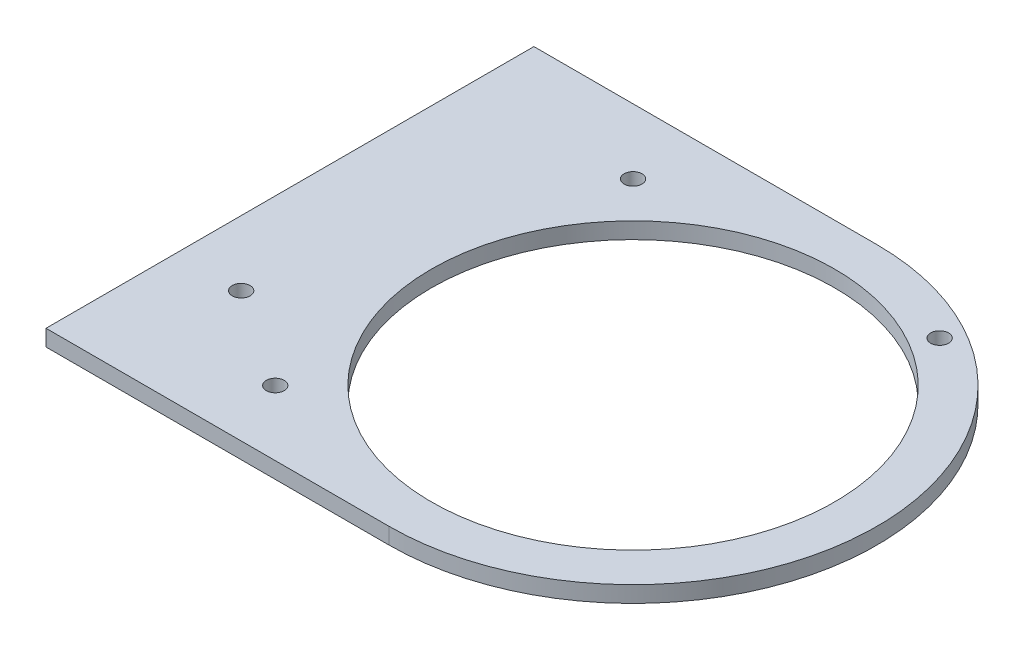
from build123d import *

# Parameters (mm, degrees)
SKETCH2_W           = 120.952956328
SKETCH2_H           = 3.175
BOSS_EXTRUDE1_DEPTH = 95.25
SKETCH3_R           = 39.37
CUT_EXTRUDE2_DEPTH  = 4.175
CUT_EXTRUDE3_DEPTH  = 4.175
SKETCH8_R           = 1.75
CUT_EXTRUDE7_DEPTH  = 4.175
SKETCH10_R          = 1.75
CUT_EXTRUDE9_DEPTH  = 4.175
SKETCH11_W          = 6.35
SKETCH11_H          = 95.25
CUT_EXTRUDE10_DEPTH = 4.175
SKETCH12_R          = 1.75
CUT_EXTRUDE11_DEPTH = 4.175


with BuildPart() as part:
    # Sketch2 → Boss-Extrude1 (new body)
    with BuildSketch(Plane.XY):
        with Locations((98.782063621, 1.5875)):
            Rectangle(SKETCH2_W, SKETCH2_H)
    extrude(amount=BOSS_EXTRUDE1_DEPTH)

    # Sketch3 → Cut-Extrude2 (cut, through all)
    with BuildSketch(Plane(origin=(0, 3.175, 0), x_dir=(1, 0, 0), z_dir=(0, 1, 0))):
        with Locations((111.633541785, -47.625)):
            Circle(SKETCH3_R)
    extrude(amount=-CUT_EXTRUDE2_DEPTH, mode=Mode.SUBTRACT)

    # Sketch4 → Cut-Extrude3 (cut, through all)
    with BuildSketch(Plane(origin=(0, 3.175, 0), x_dir=(1, 0, 0), z_dir=(0, 1, 0))):
        with BuildLine():
            Line((111.633541785, -95.25), (179.051442703, -95.25))
            Line((179.051442703, -95.25), (179.051442703, 0))
            Line((179.051442703, 0), (111.633541785, 0))
            ThreePointArc((111.633541785, 0), (159.258541785, -47.625), (111.633541785, -95.25))
        make_face()
    extrude(amount=-CUT_EXTRUDE3_DEPTH, mode=Mode.SUBTRACT)

    # Sketch8 → Cut-Extrude7 (cut, through all)
    with BuildSketch(Plane(origin=(0, 3.175, 0), x_dir=(1, 0, 0), z_dir=(0, 1, 0))):
        with Locations((76.708541785, -12.7)):
            Circle(SKETCH8_R)
        with Locations((76.708541785, -82.55)):
            Circle(SKETCH8_R)
    extrude(amount=-CUT_EXTRUDE7_DEPTH, mode=Mode.SUBTRACT)

    # Sketch10 → Cut-Extrude9 (cut, through all)
    with BuildSketch(Plane(origin=(0, 3.175, 0), x_dir=(1, 0, 0), z_dir=(0, 1, 0))):
        with Locations((133.541041785, -9.680096933)):
            Circle(SKETCH10_R)
    extrude(amount=-CUT_EXTRUDE9_DEPTH, mode=Mode.SUBTRACT)

    # Sketch11 → Cut-Extrude10 (cut, through all)
    with BuildSketch(Plane(origin=(0, 3.175, 0), x_dir=(1, 0, 0), z_dir=(0, 1, 0))):
        with Locations((41.480585457, -47.625)):
            Rectangle(SKETCH11_W, SKETCH11_H)
    extrude(amount=-CUT_EXTRUDE10_DEPTH, mode=Mode.SUBTRACT)

    # Sketch12 → Cut-Extrude11 (cut, through all)
    with BuildSketch(Plane(origin=(0, 3.175, 0), x_dir=(1, 0, 0), z_dir=(0, 1, 0))):
        with Locations((57.355585457, -69.85)):
            Circle(SKETCH12_R)
    extrude(amount=-CUT_EXTRUDE11_DEPTH, mode=Mode.SUBTRACT)


solid = part.part
